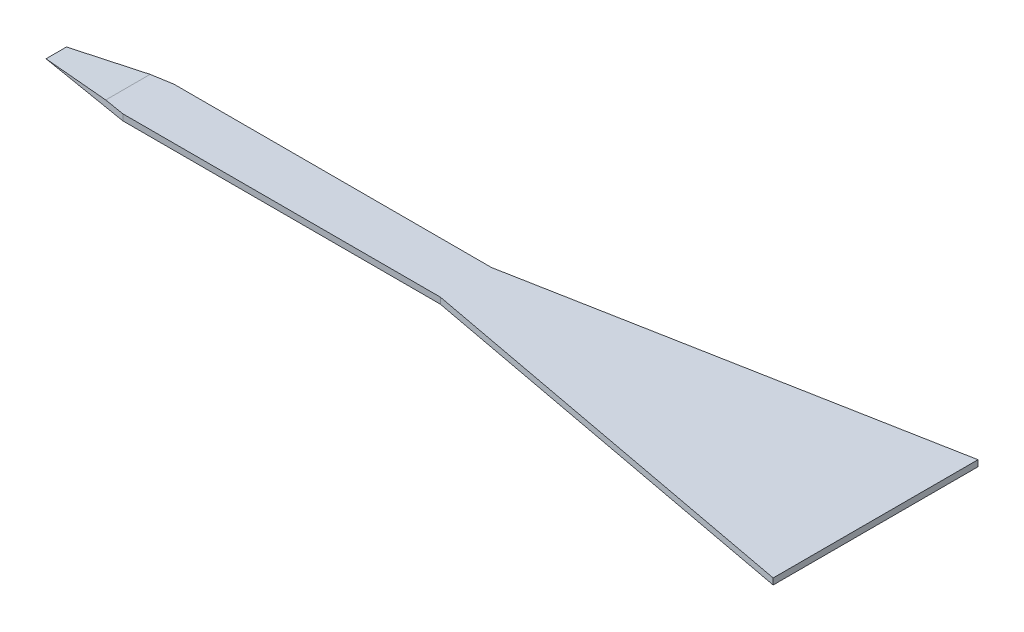
from build123d import *

# Parameters (mm, degrees)
BOSS_EXTRUDE1_DEPTH = 0.06
CUT_EXTRUDE3_DEPTH  = 9.09728967
CUT_EXTRUDE4_DEPTH  = 9.09728967


with BuildPart() as part:
    # Sketch1 → Boss-Extrude1 (new body)
    with BuildSketch(Plane(origin=(0, 0, 0), x_dir=(1, 0, 0), z_dir=(0, 1, 0))):
        with BuildLine():
            ThreePointArc((-0.362264151, -0.932075472), (-0.747576714, -0.664175471), (-0.968245837, -0.25))
            Line((-0.968245837, -0.25), (-4, -0.25))
            Line((-4, -0.25), (-0.362264151, -0.932075472))
        make_face()
        with BuildLine():
            ThreePointArc((-0.968245837, 0.25), (-0.747576714, 0.664175471), (-0.362264151, 0.932075472))
            Line((-0.362264151, 0.932075472), (-4, 0.25))
            Line((-4, 0.25), (-0.968245837, 0.25))
        make_face()
        with BuildLine():
            ThreePointArc((-0.968245837, -0.25), (-1, 0), (-0.968245837, 0.25))
            Line((-0.968245837, 0.25), (-4, 0.25))
            Line((-4, 0.25), (-8, 0.25))
            Line((-8, 0.25), (-8, -0.25))
            Line((-8, -0.25), (-4, -0.25))
            Line((-4, -0.25), (-0.968245837, -0.25))
        make_face()
        with BuildLine():
            Line((0, -1), (0, -0.25))
            Line((0, -0.25), (-0.968245837, -0.25))
            ThreePointArc((-0.968245837, -0.25), (-0.747576714, -0.664175471), (-0.362264151, -0.932075472))
            Line((-0.362264151, -0.932075472), (0, -1))
        make_face()
        with BuildLine():
            Line((0, 0.25), (0, 1))
            Line((0, 1), (-0.362264151, 0.932075472))
            ThreePointArc((-0.362264151, 0.932075472), (-0.747576714, 0.664175471), (-0.968245837, 0.25))
            Line((-0.968245837, 0.25), (0, 0.25))
        make_face()
        with BuildLine():
            Line((0, -0.25), (0, 0.25))
            Line((0, 0.25), (-0.968245837, 0.25))
            ThreePointArc((-0.968245837, 0.25), (-1, 0), (-0.968245837, -0.25))
            Line((-0.968245837, -0.25), (0, -0.25))
        make_face()
    extrude(amount=BOSS_EXTRUDE1_DEPTH)

    # Sketch5 → Cut-Extrude3 (cut, through all)
    with BuildSketch(Plane.XY.offset(0.25)):
        Polygon((-8, 0), (-8, 0.06), (-7.3, 0.06), align=None)
    extrude(amount=-CUT_EXTRUDE3_DEPTH, mode=Mode.SUBTRACT)

    # 3DSketch1 → Cut-Extrude4 (cut, through all)
    with BuildSketch(Plane(origin=(-8, 0.06, 0.25), x_dir=(0.8741572761215382, 0, -0.48564293117863155), z_dir=(0, 1, 0))):
        Polygon((0, 0), (0.07284644, 0.131123591), (0.786741549, -0.437078638), align=None)
        Polygon((1.029563014, 0), (0.242821466, 0.437078638), (0.169975026, 0.305955047), align=None)
    extrude(amount=-CUT_EXTRUDE4_DEPTH, mode=Mode.SUBTRACT)


solid = part.part
